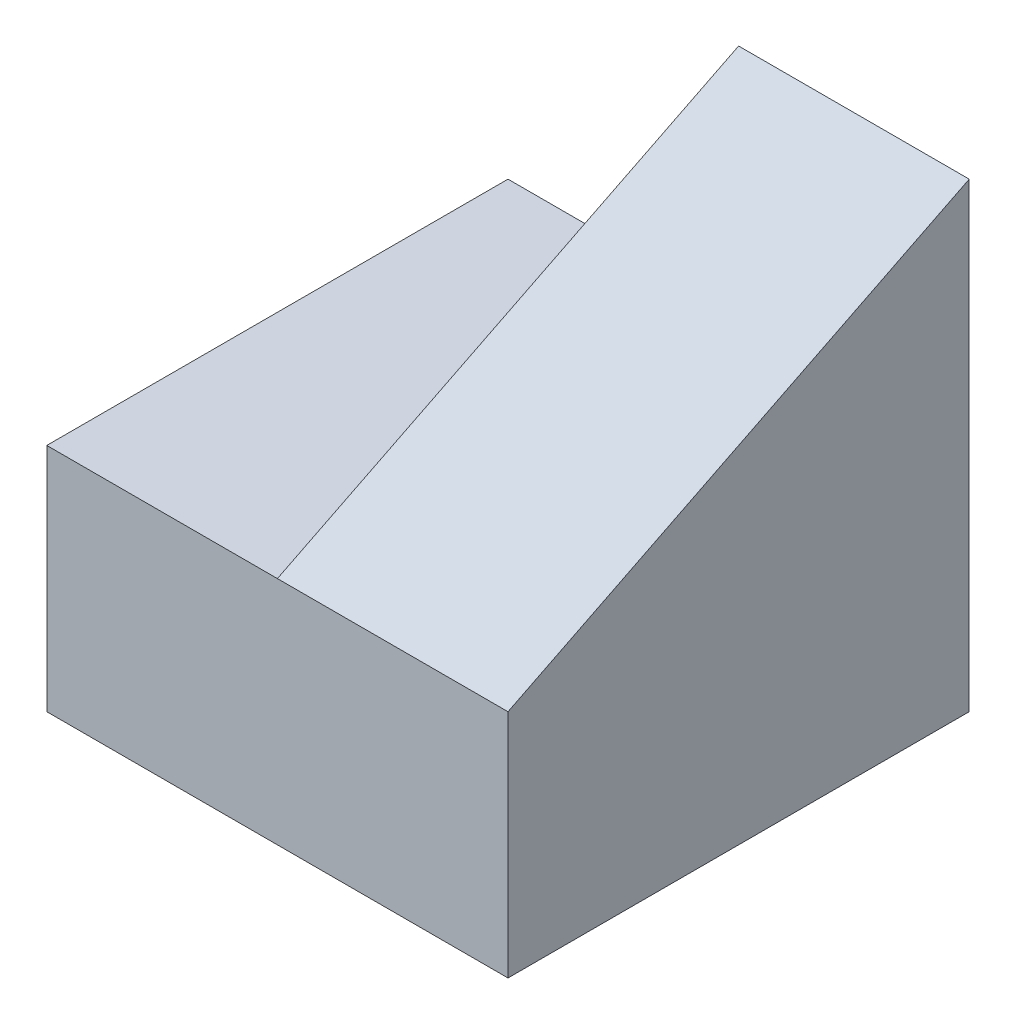
from build123d import *

# Parameters (mm, degrees)
SKETCH1_W           = 40
SKETCH1_H           = 20
BOSS_EXTRUDE1_DEPTH = 40
BOSS_EXTRUDE2_DEPTH = 20


with BuildPart() as part:
    # Sketch1 → Boss-Extrude1 (new body)
    with BuildSketch(Plane.XY):
        with Locations((20, 10)):
            Rectangle(SKETCH1_W, SKETCH1_H)
    extrude(amount=BOSS_EXTRUDE1_DEPTH)

    # Sketch2 → Boss-Extrude2 (add)
    with BuildSketch(Plane(origin=(40, 0, 0), x_dir=(0, 0, -1), z_dir=(1, 0, 0))):
        Polygon((-40, 20), (0, 20), (0, 40), align=None)
    extrude(amount=-BOSS_EXTRUDE2_DEPTH)


solid = part.part
